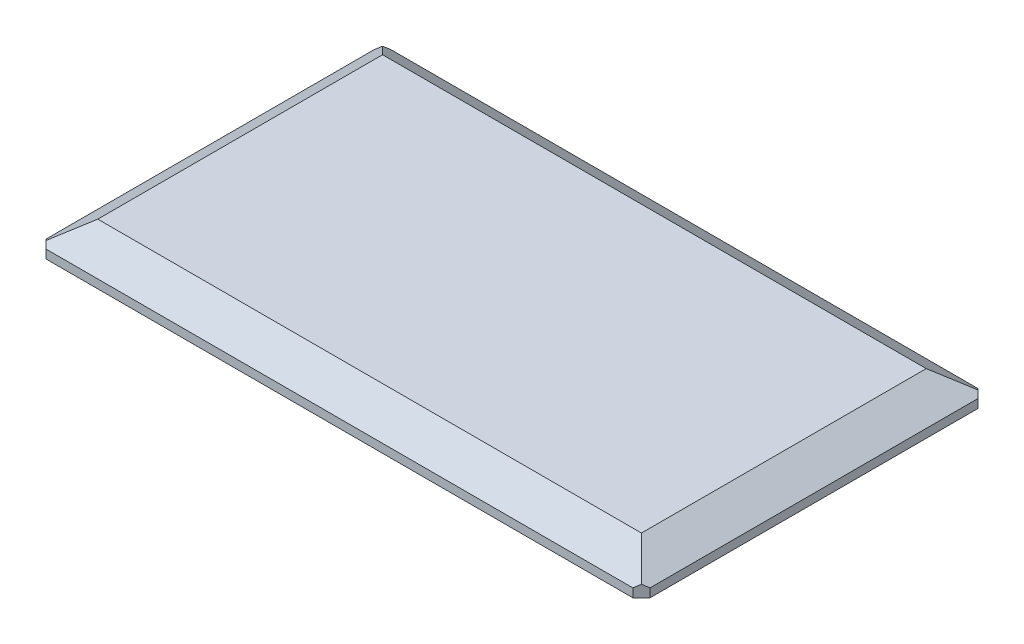
from build123d import *

# Parameters (mm, degrees)
SKETCH1_W           = 140
SKETCH1_H           = 80
BOSS_EXTRUDE1_DEPTH = 2
SKETCH3_W           = 126
SKETCH3_H           = 66
SKETCH2_W           = 140
SKETCH2_H           = 80
CHAMFER2_SIZE       = 2
SKETCH4_W           = 8
SKETCH4_H           = 10
BOSS_EXTRUDE2_DEPTH = 7
SKETCH5_R           = 2.05
CUT_EXTRUDE1_DEPTH  = 133.9000001
SKETCH6_W           = 107.8
SKETCH6_H           = 64
CUT_EXTRUDE2_DEPTH  = 5


with BuildPart() as part:
    # Sketch1 → Boss-Extrude1 (new body)
    with BuildSketch(Plane(origin=(0, 0, 0), x_dir=(1, 0, 0), z_dir=(0, 1, 0))):
        Rectangle(SKETCH1_W, SKETCH1_H)
    extrude(amount=BOSS_EXTRUDE1_DEPTH)

    # Sketch3 → Loft1 section 0
    with BuildSketch(Plane(origin=(0, 7, 0), x_dir=(1, 0, 0), z_dir=(0, 1, 0))):
        Rectangle(SKETCH3_W, SKETCH3_H)
    # Sketch2 → Loft1 section 1
    with BuildSketch(Plane(origin=(0, 2, 0), x_dir=(1, 0, 0), z_dir=(0, 1, 0))):
        Rectangle(SKETCH2_W, SKETCH2_H)
    loft()

    # Chamfer2
    chamfer2_edges = [part.edges().sort_by_distance(p)[0] for p in [
        (70, 1, 40),
        (-70, 1, 40),
        (-70, 1, -40),
        (70, 1, -40),
    ]]
    chamfer(chamfer2_edges, length=CHAMFER2_SIZE)

    # Sketch4 → Boss-Extrude2 (add)
    with BuildSketch(Plane.XZ):
        with Locations((-58.9, 20)):
            Rectangle(SKETCH4_W, SKETCH4_H)
        with Locations((-58.9, -20)):
            Rectangle(SKETCH4_W, SKETCH4_H)
        with Locations((58.9, -20)):
            Rectangle(SKETCH4_W, SKETCH4_H)
        with Locations((58.9, 20)):
            Rectangle(SKETCH4_W, SKETCH4_H)
    extrude(amount=BOSS_EXTRUDE2_DEPTH)

    # Sketch5 → Cut-Extrude1 (cut, through all)
    with BuildSketch(Plane.ZY.offset(62.9)):
        with Locations((-20, -3.5)):
            Circle(SKETCH5_R)
        with Locations((20, -3.5)):
            Circle(SKETCH5_R)
    extrude(amount=-CUT_EXTRUDE1_DEPTH, mode=Mode.SUBTRACT)

    # Sketch6 → Cut-Extrude2 (cut)
    with BuildSketch(Plane.XZ):
        Rectangle(SKETCH6_W, SKETCH6_H)
    extrude(amount=-CUT_EXTRUDE2_DEPTH, mode=Mode.SUBTRACT)


solid = part.part
